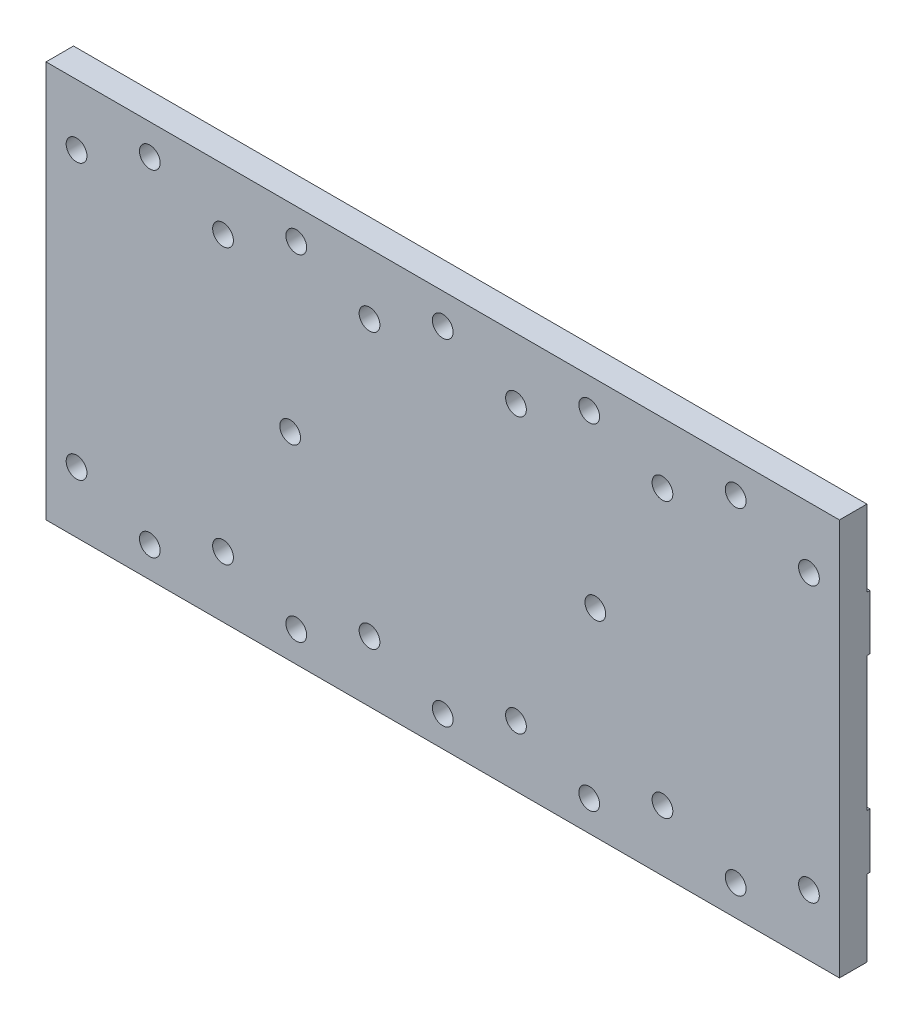
from build123d import *

# Parameters (mm, degrees)
ESQUISSE1_W             = 130
ESQUISSE1_H             = 65
ESQUISSE1_R             = 1.3
BOSS_EXTRU_1_DEPTH      = 5
ESQUISSE2_W             = 130
ESQUISSE2_H             = 12.5
ESQUISSE2_H_2           = 22
ENL_V_MAT_EXTRU_1_DEPTH = 0.5
D_GAGEMENT_M3_D         = 3.4
D_GAGEMENT_M3_DEPTH     = 6.978536948
D_GAGEMENT_M3_TIP       = 1.021463052
D_GAGEMENT_M32_D        = 3.4
D_GAGEMENT_M32_DEPTH    = 6.978536948
D_GAGEMENT_M32_TIP      = 1.021463052


with BuildPart() as part:
    # Esquisse1 → Boss.-Extru.1 (new body)
    with BuildSketch(Plane.XY):
        with Locations((65, 32.5)):
            Rectangle(ESQUISSE1_W, ESQUISSE1_H)
        with Locations((113, 5)):
            Circle(ESQUISSE1_R, mode=Mode.SUBTRACT)
        with Locations((89, 5)):
            Circle(ESQUISSE1_R, mode=Mode.SUBTRACT)
        with Locations((65, 5)):
            Circle(ESQUISSE1_R, mode=Mode.SUBTRACT)
        with Locations((41, 5)):
            Circle(ESQUISSE1_R, mode=Mode.SUBTRACT)
        with Locations((17, 5)):
            Circle(ESQUISSE1_R, mode=Mode.SUBTRACT)
        with Locations((113, 60)):
            Circle(ESQUISSE1_R, mode=Mode.SUBTRACT)
        with Locations((89, 60)):
            Circle(ESQUISSE1_R, mode=Mode.SUBTRACT)
        with Locations((65, 60)):
            Circle(ESQUISSE1_R, mode=Mode.SUBTRACT)
        with Locations((41, 60)):
            Circle(ESQUISSE1_R, mode=Mode.SUBTRACT)
        with Locations((17, 60)):
            Circle(ESQUISSE1_R, mode=Mode.SUBTRACT)
    extrude(amount=BOSS_EXTRU_1_DEPTH)

    # Esquisse2 → Enlèv. mat.-Extru.1 (cut)
    with BuildSketch(Plane(origin=(0, 0, 0), x_dir=(-1, 0, 0), z_dir=(0, 0, -1))):
        with Locations((-65, 58.75)):
            Rectangle(ESQUISSE2_W, ESQUISSE2_H)
        with Locations((-65, 6.25)):
            Rectangle(ESQUISSE2_W, ESQUISSE2_H)
        with Locations((-65, 32.5)):
            Rectangle(ESQUISSE2_W, ESQUISSE2_H_2)
    extrude(amount=-ENL_V_MAT_EXTRU_1_DEPTH, mode=Mode.SUBTRACT)

    # Dégagement M3
    with Locations(Plane.XY.offset(5)):
        with Locations((17, 60), (41, 60), (65, 60), (89, 60), (113, 60), (113, 5), (89, 5), (65, 5), (41, 5), (17, 5)):
            Hole(D_GAGEMENT_M3_D / 2, depth=D_GAGEMENT_M3_DEPTH)
            with Locations((0, 0, -(D_GAGEMENT_M3_DEPTH + D_GAGEMENT_M3_TIP / 2))):  # 118° drill point
                Cone(0, D_GAGEMENT_M3_D / 2, D_GAGEMENT_M3_TIP, mode=Mode.SUBTRACT)

    # Dégagement M32
    with Locations(Plane(origin=(0, 0, 0.5), x_dir=(-1, 0, 0), z_dir=(0, 0, -1))):
        with Locations((-125, 55), (-101, 55), (-77, 55), (-53, 55), (-29, 55), (-5, 55), (-40, 32.5), (-90, 32.5), (-125, 10), (-101, 10), (-77, 10), (-53, 10), (-29, 10), (-5, 10)):
            Hole(D_GAGEMENT_M32_D / 2, depth=D_GAGEMENT_M32_DEPTH)
            with Locations((0, 0, -(D_GAGEMENT_M32_DEPTH + D_GAGEMENT_M32_TIP / 2))):  # 118° drill point
                Cone(0, D_GAGEMENT_M32_D / 2, D_GAGEMENT_M32_TIP, mode=Mode.SUBTRACT)


solid = part.part
